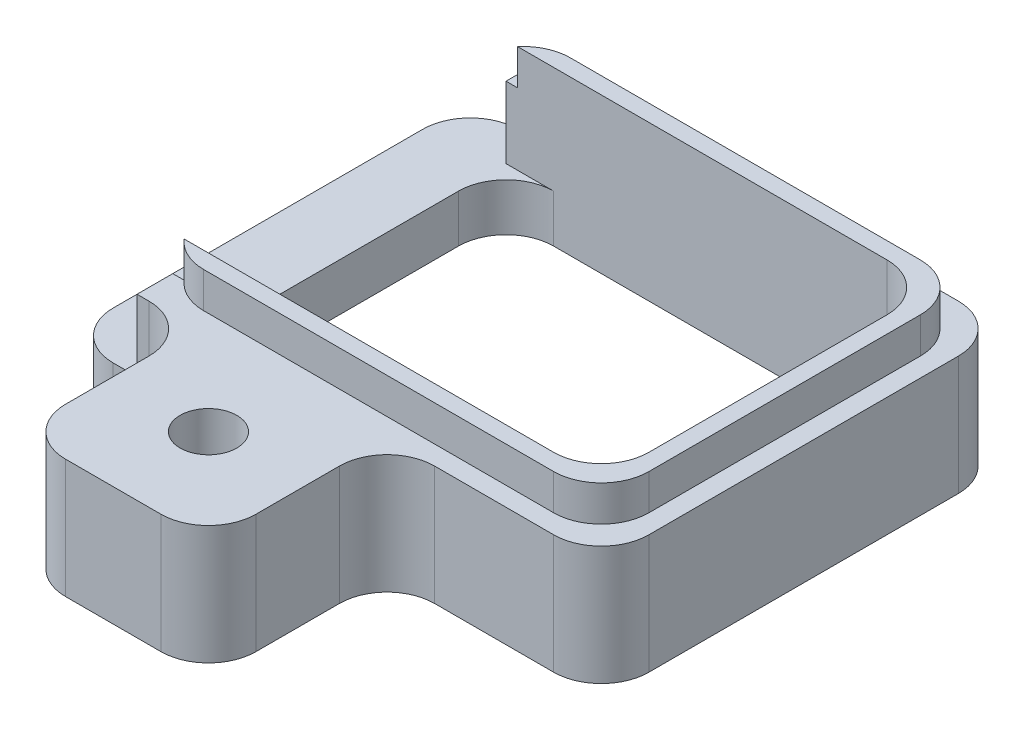
from build123d import *

# Parameters (mm, degrees)
SKETCH5_W                 = 11.25
SKETCH5_H                 = 8.5
EXTRUDE4_DEPTH            = 2.5
SKETCH19_W                = 1.5
SKETCH19_H                = 8.5
EXTRUDE12_DEPTH           = 1.5
SKETCH21_W                = 9
SKETCH21_H                = 7
EXTRUDE13_DEPTH           = 3.5
SKETCH22_W                = 4
SKETCH22_H                = 2.5
EXTRUDE14_DEPTH           = 3.75
EXTRUDE15_DEPTH           = 0.75
F_0_80_TAPPED_HOLE1_D     = 1.19126
F_0_80_TAPPED_HOLE1_DEPTH = 79.01
F_0_80_TAPPED_HOLE1_TIP   = 0.357890611
FILLET4_R                 = 1
EXTRUDE16_DEPTH           = 0.75
EXTRUDE17_DEPTH           = 0.75


with BuildPart() as part:
    # Sketch5 → Extrude4 (new body)
    with BuildSketch(Plane(origin=(0, 0, 0), x_dir=(1, 0, 0), z_dir=(0, 1, 0))):
        Rectangle(SKETCH5_W, SKETCH5_H)
    extrude(amount=EXTRUDE4_DEPTH)

    # Sketch19 → Extrude12 (cut)
    with BuildSketch(Plane(origin=(0, 2.5, 0), x_dir=(-1, 0, 0), z_dir=(0, 1, 0))):
        with Locations((4.875, 0)):
            Rectangle(SKETCH19_W, SKETCH19_H)
    extrude(amount=-EXTRUDE12_DEPTH, mode=Mode.SUBTRACT)

    # Sketch21 → Extrude13 (cut, through all)
    with BuildSketch(Plane(origin=(0, 2.5, 0), x_dir=(-1, 0, 0), z_dir=(0, 1, 0))):
        with Locations((-0.375, 0)):
            Rectangle(SKETCH21_W, SKETCH21_H)
    extrude(amount=-EXTRUDE13_DEPTH, mode=Mode.SUBTRACT)

    # Sketch22 → Extrude14 (add)
    with BuildSketch(Plane.XY.offset(4.25)):
        with Locations((-0.875, 1.25)):
            Rectangle(SKETCH22_W, SKETCH22_H)
    extrude(amount=EXTRUDE14_DEPTH)

    # Sketch24 → Extrude15 (add)
    with BuildSketch(Plane(origin=(0, 2.5, 0), x_dir=(1, 0, 0), z_dir=(0, 1, 0))):
        Polygon((-4.125, 3.85), (-4.125, 3.5), (4.875, 3.5), (4.875, -3.5), (-4.125, -3.5), (-4.125, -3.85), (5.225, -3.85), (5.225, 3.85), align=None)
    extrude(amount=EXTRUDE15_DEPTH)

    # #0-80 Tapped Hole1
    with Locations(Plane(origin=(-0.875, 2.5, 6), x_dir=(0, 0, 1), z_dir=(0, 1, 0))):
        with Locations((0, 0)):
            Hole(F_0_80_TAPPED_HOLE1_D / 2, depth=F_0_80_TAPPED_HOLE1_DEPTH)
            with Locations((0, 0, -(F_0_80_TAPPED_HOLE1_DEPTH + F_0_80_TAPPED_HOLE1_TIP / 2))):  # 118° drill point
                Cone(0, F_0_80_TAPPED_HOLE1_D / 2, F_0_80_TAPPED_HOLE1_TIP, mode=Mode.SUBTRACT)

    # Fillet4
    fillet4_edges = [part.edges().sort_by_distance(p)[0] for p in [
        (5.625, 1.25, -4.25),
        (5.225, 2.875, -3.85),
        (5.625, 1.25, 4.25),
        (5.225, 2.875, 3.85),
        (4.875, 1.625, 3.5),
        (4.875, 1.625, -3.5),
        (-4.125, 0.5, 3.5),
        (-4.125, 0.5, -3.5),
        (-5.625, 0.5, -4.25),
        (-5.625, 0.5, 4.25),
        (-2.875, 1.25, 4.25),
        (-2.875, 1.25, 8),
        (1.125, 1.25, 8),
        (1.125, 1.25, 4.25),
    ]]
    fillet(fillet4_edges, radius=FILLET4_R)

    # Sketch28 → Extrude16 (cut)
    with BuildSketch(Plane(origin=(0, 3.25, 0), x_dir=(-1, 0, 0), z_dir=(0, 1, 0))):
        with BuildLine():
            Line((3.125, -3.85), (4.125, -3.85))
            Line((4.125, -3.85), (4.125, -2.85))
            ThreePointArc((4.125, -2.85), (3.832106781, -3.557106781), (3.125, -3.85))
        make_face()
    extrude(amount=-EXTRUDE16_DEPTH, mode=Mode.SUBTRACT)

    # Sketch31 → Extrude17 (cut)
    with BuildSketch(Plane(origin=(0, 3.25, 0), x_dir=(-1, 0, 0), z_dir=(0, 1, 0))):
        with BuildLine():
            Line((4.125, 2.85), (4.125, 3.85))
            Line((4.125, 3.85), (3.125, 3.85))
            ThreePointArc((3.125, 3.85), (3.832106781, 3.557106781), (4.125, 2.85))
        make_face()
    extrude(amount=-EXTRUDE17_DEPTH, mode=Mode.SUBTRACT)


solid = part.part
